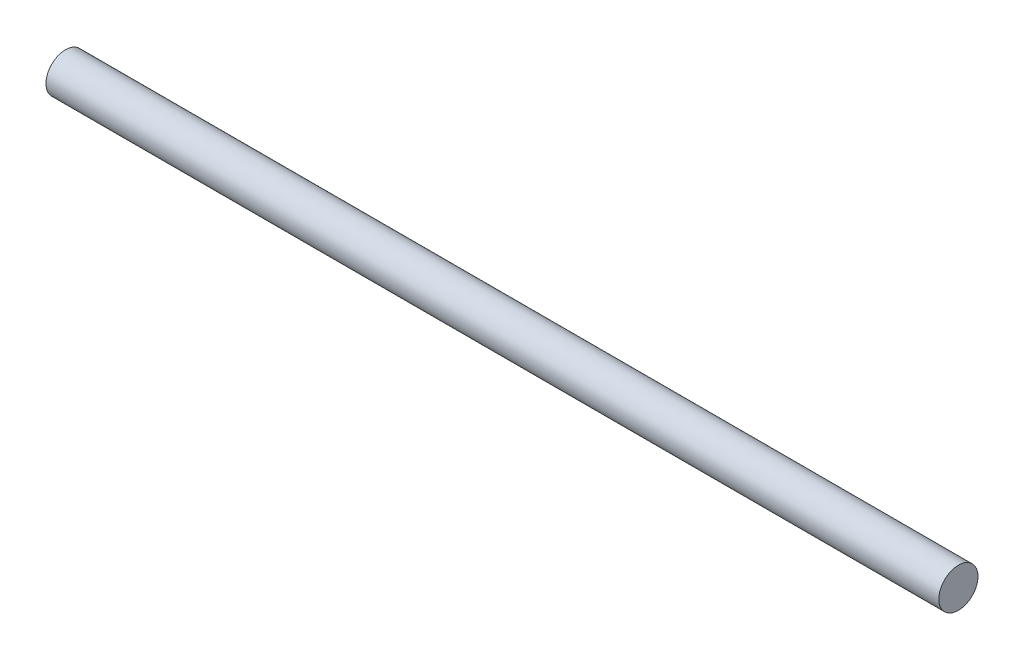
from build123d import *

# Parameters (mm, degrees)
SKETCH1_R           = 3.96875
BOSS_EXTRUDE1_DEPTH = 90.4875


with BuildPart() as part:
    # Sketch1 → Boss-Extrude1 (new body, symmetric)
    with BuildSketch(Plane(origin=(0, 0, 0), x_dir=(0, 0, -1), z_dir=(1, 0, 0))):
        Circle(SKETCH1_R)
    extrude(amount=BOSS_EXTRUDE1_DEPTH, both=True)


solid = part.part
